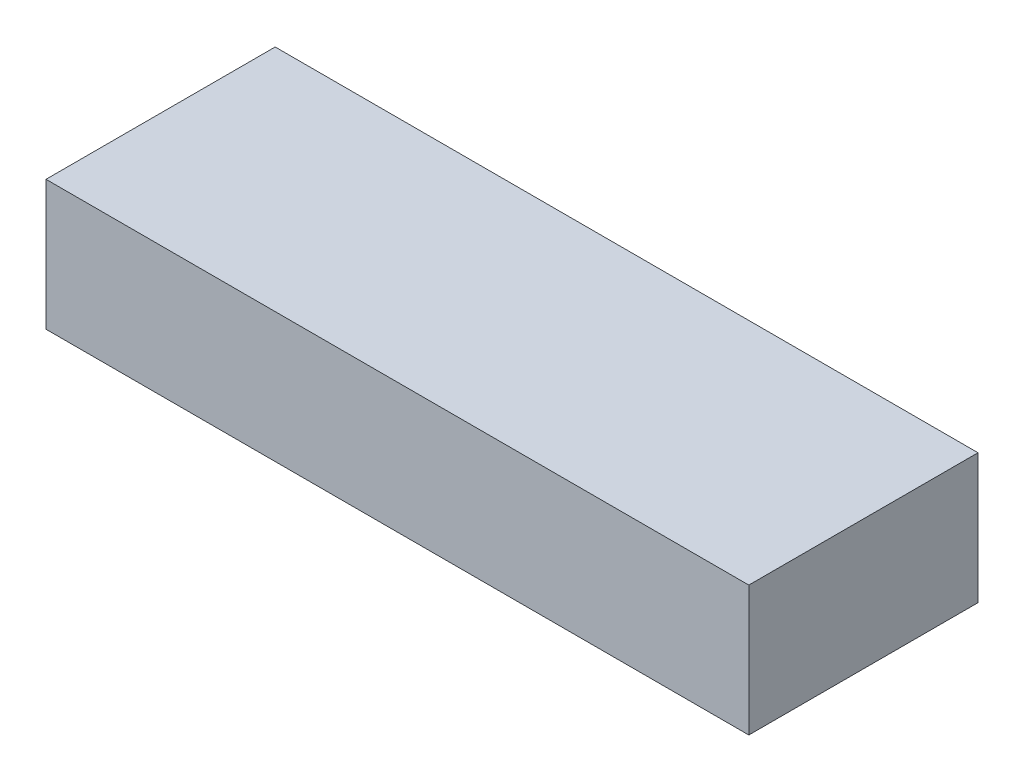
from build123d import *

# Parameters (mm, degrees)
ESBO_O1_W                = 46
ESBO_O1_H                = 15
RESSALTO_EXTRUS_O1_DEPTH = 8.5


with BuildPart() as part:
    # Esboço1 → Ressalto-extrusão1 (new body)
    with BuildSketch(Plane(origin=(0, 0, 0), x_dir=(1, 0, 0), z_dir=(0, 1, 0))):
        Rectangle(ESBO_O1_W, ESBO_O1_H)
    extrude(amount=RESSALTO_EXTRUS_O1_DEPTH)


solid = part.part
